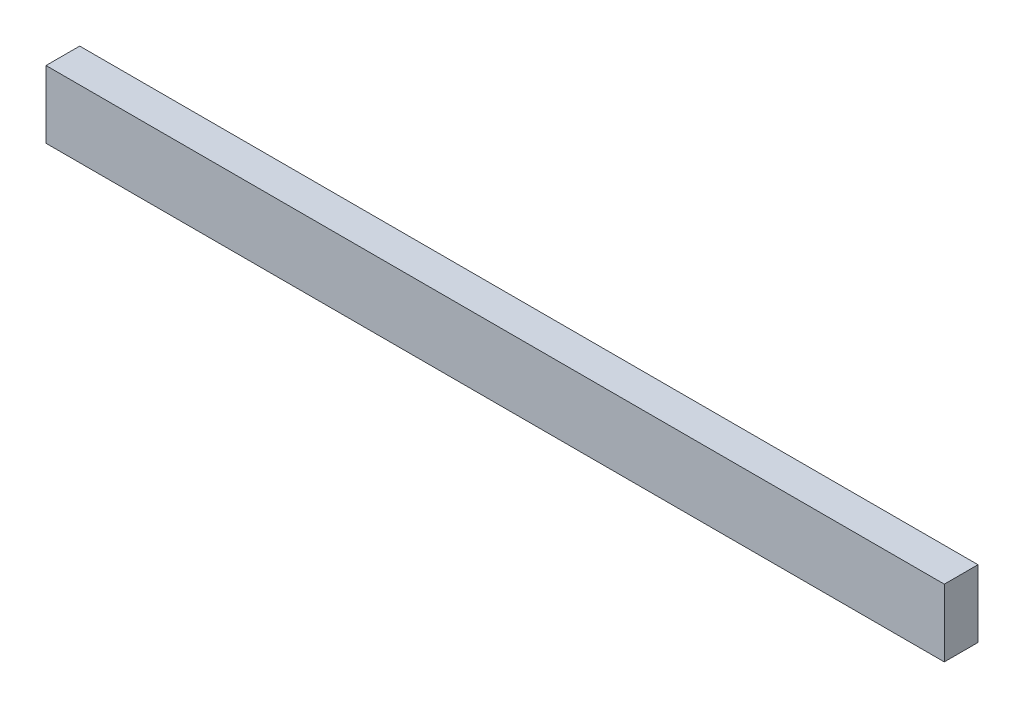
from build123d import *

# Parameters (mm, degrees)
SKETCH2_W           = 80
SKETCH2_H           = 6
BOSS_EXTRUDE1_DEPTH = 3


with BuildPart() as part:
    # Sketch2 → Boss-Extrude1 (new body)
    with BuildSketch(Plane.XY):
        Rectangle(SKETCH2_W, SKETCH2_H)
    extrude(amount=BOSS_EXTRUDE1_DEPTH)


solid = part.part
